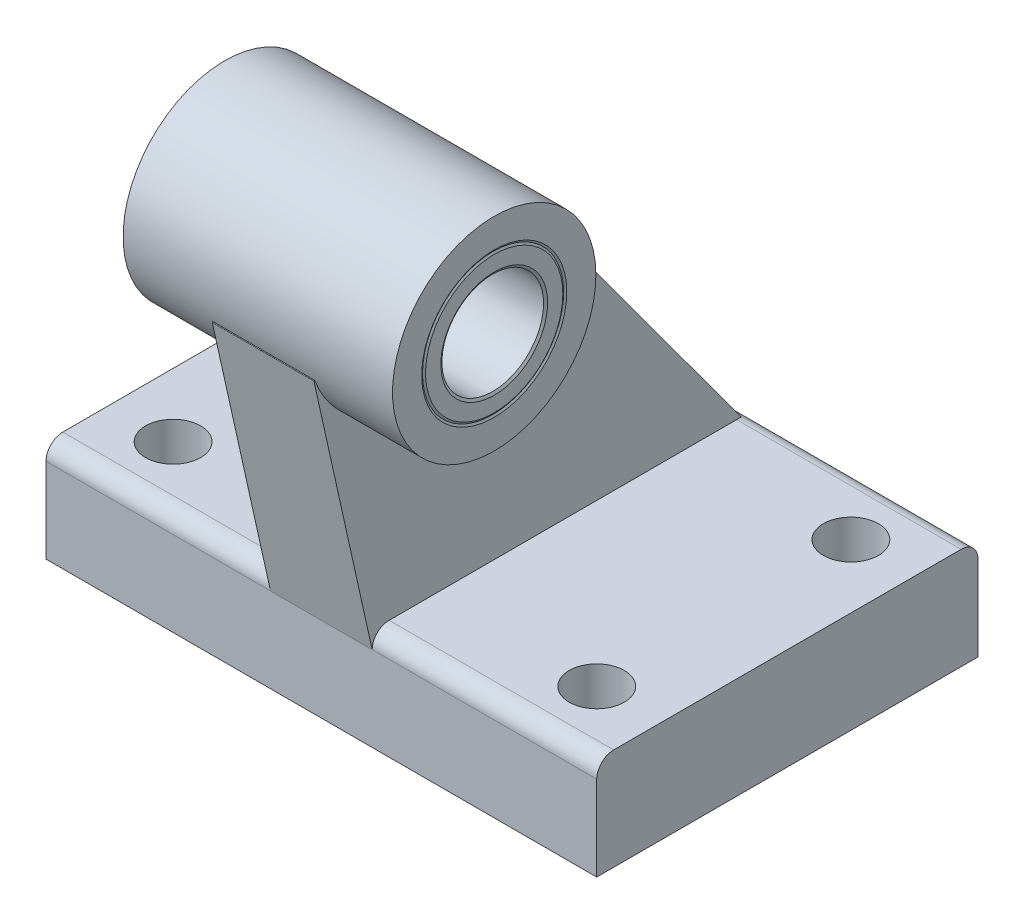
from build123d import *

# Parameters (mm, degrees)
BOSS_EXTRUDE1_DEPTH      = 32.5
BOSS_EXTRUDE1_DEPTH_BACK = 32.5
BOSS_EXTRUDE2_DEPTH      = 6
BOSS_EXTRUDE2_DEPTH_BACK = 6
BOSS_EXTRUDE3_DEPTH      = 15.9
BOSS_EXTRUDE3_DEPTH_BACK = 15.9
SKETCH3_R                = 12
SKETCH4_W                = 3.25
SKETCH4_H                = 12
SKETCH5_W                = 3.25
SKETCH5_H                = 12
SKETCH6_W                = 3.25
SKETCH6_H                = 12
SKETCH7_W                = 3.25
SKETCH7_H                = 12


with BuildPart() as part:
    # Sketch1 → Boss-Extrude1 (new, two sides: drawn at the far end of the back side and taken through both)
    with BuildSketch(Plane(origin=(0, 0, 0), x_dir=(0, 0, -1), z_dir=(1, 0, 0)).offset(-BOSS_EXTRUDE1_DEPTH_BACK)):
        with BuildLine():
            Line((-22.5, 10.008), (-22.5, 0))
            Line((-22.5, 0), (22.5, 0))
            Line((22.5, 0), (22.5, 10.008))
            ThreePointArc((22.5, 10.008), (21.916556708, 11.416556708), (20.508, 12))
            Line((20.508, 12), (-20.508, 12))
            ThreePointArc((-20.508, 12), (-21.916556708, 11.416556708), (-22.5, 10.008))
        make_face()
    extrude(amount=BOSS_EXTRUDE1_DEPTH + BOSS_EXTRUDE1_DEPTH_BACK)

    # Sketch2 → Boss-Extrude2 (add, two sides: drawn at the far end of the back side and taken through both)
    with BuildSketch(Plane(origin=(0, 0, 0), x_dir=(0, 0, -1), z_dir=(1, 0, 0)).offset(-BOSS_EXTRUDE2_DEPTH_BACK)):
        with BuildLine():
            Line((-29.376798431, 40.880721246), (-22.5, 9.984))
            ThreePointArc((-22.5, 9.984), (-21.909527271, 11.409527271), (-20.484, 12))
            Line((-20.484, 12), (21.041171881, 12))
            Line((21.041171881, 12), (-7.403239928, 50.840263348))
            ThreePointArc((-7.403239928, 50.840263348), (-7.470461582, 50.852879627), (-7.487381792, 50.786610269))
            ThreePointArc((-7.487381792, 50.786610269), (-13.04609099, 34.070279714), (-29.280988595, 40.908631486))
            ThreePointArc((-29.280988595, 40.908631486), (-29.341976877, 40.939588733), (-29.376798431, 40.880721246))
        make_face()
    extrude(amount=BOSS_EXTRUDE2_DEPTH + BOSS_EXTRUDE2_DEPTH_BACK)

    # Sketch3 → Boss-Extrude3 (add, two sides: drawn at the far end of the back side and taken through both)
    with BuildSketch(Plane(origin=(0, 0, 0), x_dir=(0, 0, -1), z_dir=(1, 0, 0)).offset(-BOSS_EXTRUDE3_DEPTH_BACK)):
        with Locations((-18, 45)):
            Circle(SKETCH3_R)
    extrude(amount=BOSS_EXTRUDE3_DEPTH + BOSS_EXTRUDE3_DEPTH_BACK)

    # Sketch4 → Cut-Revolve1 (revolve, cut)
    with BuildSketch(Plane.XY.offset(15)):
        with Locations((-26.625, 6)):
            Rectangle(SKETCH4_W, SKETCH4_H)
    revolve(axis=Axis((-25, 12, 15), (0, -1, 0)), mode=Mode.SUBTRACT)

    # Sketch5 → Cut-Revolve2 (revolve, cut)
    with BuildSketch(Plane.XY.offset(15)):
        with Locations((23.375, 6)):
            Rectangle(SKETCH5_W, SKETCH5_H)
    revolve(axis=Axis((25, 12, 15), (0, -1, 0)), mode=Mode.SUBTRACT)

    # Sketch6 → Cut-Revolve3 (revolve, cut)
    with BuildSketch(Plane.XY.offset(-15)):
        with Locations((-26.625, 6)):
            Rectangle(SKETCH6_W, SKETCH6_H)
    revolve(axis=Axis((-25, 12, -15), (0, -1, 0)), mode=Mode.SUBTRACT)

    # Sketch7 → Cut-Revolve4 (revolve, cut)
    with BuildSketch(Plane.XY.offset(-15)):
        with Locations((23.375, 6)):
            Rectangle(SKETCH7_W, SKETCH7_H)
    revolve(axis=Axis((25, 12, -15), (0, -1, 0)), mode=Mode.SUBTRACT)

    # Sketch8 → Cut-Revolve5 (revolve, cut)
    with BuildSketch(Plane.XY.offset(18)):
        Polygon((-15.9, 45), (-15.9, 53.564), (-15.611324865, 53.064), (15.611324865, 53.064), (15.9, 53.564), (15.9, 45), align=None)
    revolve(axis=Axis((15.9, 45, 18), (-1, 0, 0)), mode=Mode.SUBTRACT)

    # Sketch9 → Revolve1 (revolve)
    with BuildSketch(Plane.XY.offset(18)):
        Polygon((-15.9, 51.3), (-15.726794919, 51), (15.726794919, 51), (15.9, 51.3), (15.9, 53.1), (15.726794919, 53.4), (-15.726794919, 53.4), (-15.9, 53.1), align=None)
    revolve(axis=Axis((15.9, 45, 18), (-1, 0, 0)))


solid = part.part
